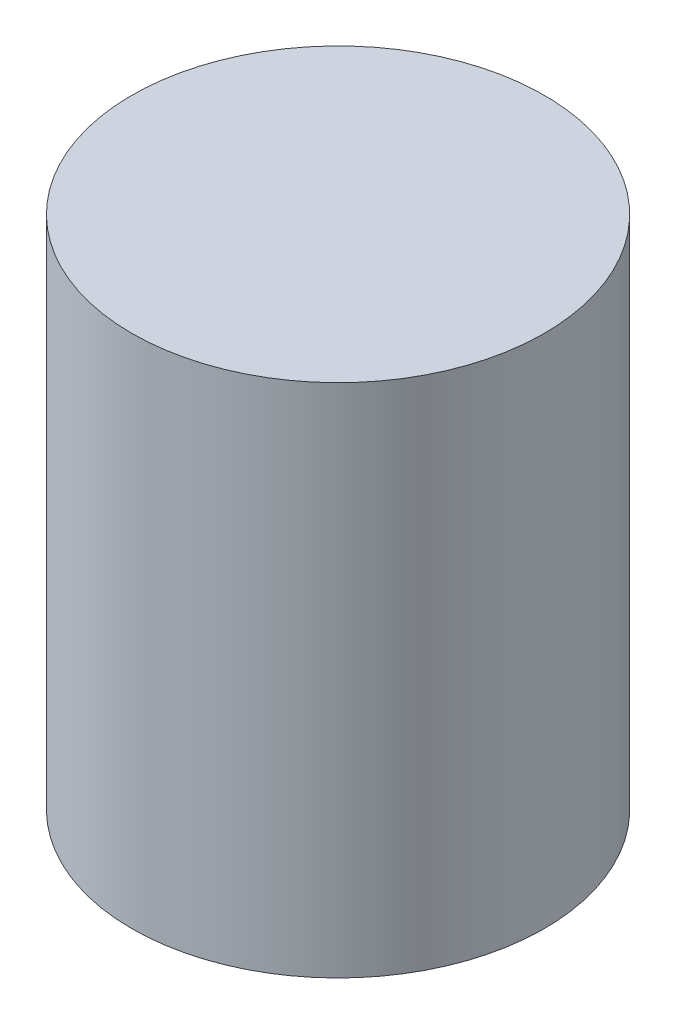
from build123d import *

# Parameters (mm, degrees)
SKETCH1_R           = 3.81
BOSS_EXTRUDE1_DEPTH = 9.525


with BuildPart() as part:
    # Sketch1 → Boss-Extrude1 (new body)
    with BuildSketch(Plane(origin=(0, 0, 0), x_dir=(1, 0, 0), z_dir=(0, 1, 0))):
        Circle(SKETCH1_R)
    extrude(amount=BOSS_EXTRUDE1_DEPTH)


solid = part.part
